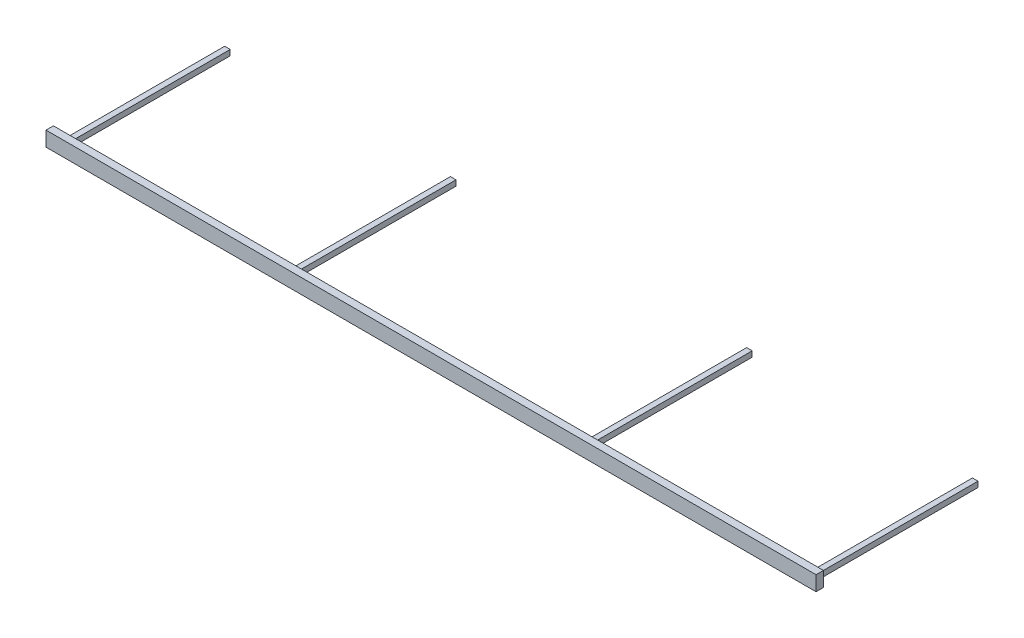
from build123d import *

# Parameters (mm, degrees)
SKETCH1_W           = 25.4
SKETCH1_H           = 50.8
SKETCH1_W_2         = 20.32
SKETCH1_H_2         = 45.72
BOSS_EXTRUDE1_DEPTH = 1314.45
SKETCH2_W           = 25.4
SKETCH2_H           = 50.8
BOSS_EXTRUDE2_DEPTH = 6.35
SKETCH3_W           = 25.4
SKETCH3_H           = 50.8
BOSS_EXTRUDE3_DEPTH = 6.35
SKETCH4_W           = 19.05
SKETCH4_H           = 19.05
SKETCH4_W_2         = 12.7
SKETCH4_H_2         = 12.7
BOSS_EXTRUDE4_DEPTH = 558.8


with BuildPart() as part:
    # Sketch1 → Boss-Extrude1 (new body, symmetric)
    with BuildSketch(Plane(origin=(0, 0, 0), x_dir=(0, 0, -1), z_dir=(1, 0, 0))):
        Rectangle(SKETCH1_W, SKETCH1_H)
        Rectangle(SKETCH1_W_2, SKETCH1_H_2, mode=Mode.SUBTRACT)
    extrude(amount=BOSS_EXTRUDE1_DEPTH, both=True)

    # Sketch2 → Boss-Extrude2 (add)
    with BuildSketch(Plane(origin=(1314.45, 0, 0), x_dir=(0, 0, -1), z_dir=(1, 0, 0))):
        Rectangle(SKETCH2_W, SKETCH2_H)
    extrude(amount=BOSS_EXTRUDE2_DEPTH)

    # Sketch3 → Boss-Extrude3 (add)
    with BuildSketch(Plane.ZY.offset(1314.45)):
        Rectangle(SKETCH3_W, SKETCH3_H)
    extrude(amount=BOSS_EXTRUDE3_DEPTH)

    # Sketch4 → Boss-Extrude4 (add)
    with BuildSketch(Plane(origin=(0, 0, -12.7), x_dir=(-1, 0, 0), z_dir=(0, 0, -1))):
        with Locations((-1282.573, -12.7)):
            Rectangle(SKETCH4_W, SKETCH4_H)
        with Locations((-1282.573, -12.7)):
            Rectangle(SKETCH4_W_2, SKETCH4_H_2, mode=Mode.SUBTRACT)
        with Locations((-508, -12.7)):
            Rectangle(SKETCH4_W, SKETCH4_H)
        with Locations((-508, -12.7)):
            Rectangle(SKETCH4_W_2, SKETCH4_H_2, mode=Mode.SUBTRACT)
        with Locations((1282.573, -12.7)):
            Rectangle(SKETCH4_W, SKETCH4_H)
        with Locations((1282.573, -12.7)):
            Rectangle(SKETCH4_W_2, SKETCH4_H_2, mode=Mode.SUBTRACT)
        with Locations((508, -12.7)):
            Rectangle(SKETCH4_W, SKETCH4_H)
        with Locations((508, -12.7)):
            Rectangle(SKETCH4_W_2, SKETCH4_H_2, mode=Mode.SUBTRACT)
    extrude(amount=BOSS_EXTRUDE4_DEPTH)


solid = part.part
